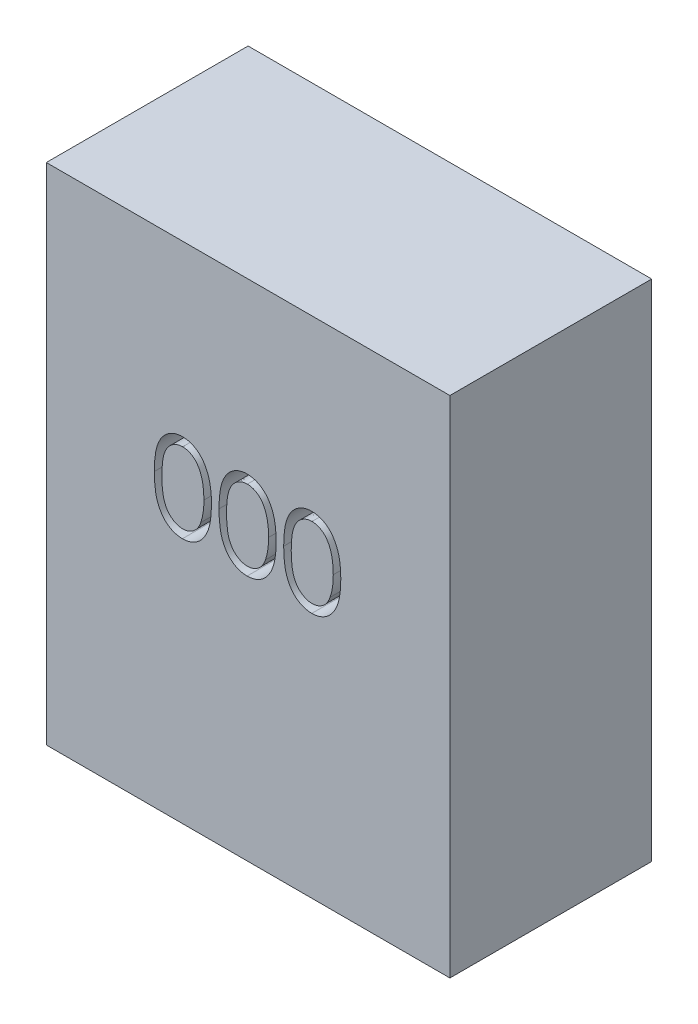
from build123d import *

# Parameters (mm, degrees)
SKETCH1_W           = 24
SKETCH1_H           = 30
BOSS_EXTRUDE1_DEPTH = 12
CUT_EXTRUDE1_DEPTH  = 2


with BuildPart() as part:
    # Sketch1 → Boss-Extrude1 (new body)
    with BuildSketch(Plane.XY):
        Rectangle(SKETCH1_W, SKETCH1_H)
    extrude(amount=BOSS_EXTRUDE1_DEPTH)

    # Sketch2 → Cut-Extrude1 (cut)
    with BuildSketch(Plane.XY.offset(12)):
        with BuildLine():
            add(Edge.make_bspline(
                [(-5.576923077, 2.298475802), (-5.57645448, 2.378614927), (-5.575544222, 2.534286333), (-5.565417907, 2.761121536), (-5.548595989, 2.973921949), (-5.525542599, 3.172697757), (-5.497488342, 3.357500278), (-5.460037647, 3.527835645), (-5.417447929, 3.684492226), (-5.368087292, 3.827980867), (-5.31239045, 3.960234728), (-5.251770078, 4.083699302), (-5.183820372, 4.198187776), (-5.112424782, 4.305527477), (-5.034693251, 4.403961327), (-4.952837836, 4.494879416), (-4.863663727, 4.576180488), (-4.770202287, 4.650246634), (-4.671607337, 4.715174451), (-4.570689243, 4.772364078), (-4.466753377, 4.821221031), (-4.359515973, 4.859635939), (-4.249940891, 4.89136572), (-4.137645081, 4.913064217), (-4.022443133, 4.926716943), (-3.94468394, 4.928022183), (-3.905248397, 4.928684135)],
                knots=[0, 0, 0, 0, 0.000240403, 0.000466987, 0.000681007, 0.000880658, 0.001067227, 0.001241486, 0.001403563, 0.001554021, 0.001696326, 0.001833841, 0.001966284, 0.002095459, 0.002220291, 0.00234224, 0.002462035, 0.002581859, 0.002699644, 0.002815804, 0.002929622, 0.00304369, 0.003157195, 0.003271518, 0.00338644, 0.003504697, 0.003504697, 0.003504697, 0.003504697], degree=3))
            add(Edge.make_bspline(
                [(-3.905248397, 4.928684135), (-3.865483428, 4.927987256), (-3.786403415, 4.926601383), (-3.669488594, 4.913281465), (-3.555274763, 4.891179861), (-3.44424885, 4.859864183), (-3.33549887, 4.821013216), (-3.22987543, 4.772317335), (-3.126722456, 4.715633239), (-3.027679188, 4.6490277), (-2.931658309, 4.574767305), (-2.841018362, 4.490820635), (-2.755751097, 4.398035322), (-2.674786375, 4.297404088), (-2.600421236, 4.186996824), (-2.529602047, 4.06873381), (-2.466213424, 3.94054686), (-2.405163888, 3.804574763), (-2.352468193, 3.657055251), (-2.304944985, 3.498819878), (-2.266546459, 3.327999612), (-2.234561784, 3.14549069), (-2.209783361, 2.950622856), (-2.19173673, 2.743813834), (-2.182203751, 2.524927562), (-2.180408464, 2.375273492), (-2.179487179, 2.298475802)],
                knots=[0, 0, 0, 0, 0.000119258, 0.000237167, 0.000352473, 0.000467905, 0.000582915, 0.000698551, 0.00081646, 0.000935634, 0.001056247, 0.001180288, 0.001305745, 0.001434012, 0.001567361, 0.001704781, 0.001847224, 0.001996109, 0.002151681, 0.002316787, 0.002491483, 0.002676571, 0.002872488, 0.003080602, 0.003299181, 0.003529585, 0.003529585, 0.003529585, 0.003529585], degree=3))
            add(Edge.make_bspline(
                [(-2.179487179, 2.298475802), (-2.180418015, 2.222013076), (-2.182231709, 2.073028573), (-2.191629861, 1.85512718), (-2.210142191, 1.649415689), (-2.233299318, 1.455400743), (-2.265372122, 1.273889859), (-2.304808074, 1.104254933), (-2.348594249, 0.945763402), (-2.402643955, 0.799713671), (-2.461802113, 0.664068352), (-2.526166679, 0.537400998), (-2.595123573, 0.418592008), (-2.670250352, 0.30859237), (-2.750326656, 0.20662286), (-2.837066354, 0.114483399), (-2.928024333, 0.029953867), (-3.024327784, -0.045262743), (-3.124915715, -0.111098179), (-3.227714396, -0.169975108), (-3.334547801, -0.217450386), (-3.442994876, -0.258214731), (-3.554606828, -0.289358233), (-3.669244529, -0.310892313), (-3.786324866, -0.325994953), (-3.865469959, -0.327147067), (-3.905248397, -0.327726122)],
                knots=[0, 0, 0, 0, 0.000229402, 0.00044698, 0.000654097, 0.000848895, 0.001032996, 0.001206716, 0.001371263, 0.001525893, 0.001673458, 0.001815007, 0.001951919, 0.002085268, 0.002214319, 0.002340458, 0.002464499, 0.002586517, 0.002706526, 0.002824923, 0.002941471, 0.003056825, 0.003172257, 0.003288547, 0.00340657, 0.003525828, 0.003525828, 0.003525828, 0.003525828], degree=3))
            add(Edge.make_bspline(
                [(-3.905248397, -0.327726122), (-3.944682846, -0.327059899), (-4.022439881, -0.32574624), (-4.137657632, -0.312155195), (-4.249489694, -0.290304476), (-4.358487914, -0.259709327), (-4.465211507, -0.222259561), (-4.568206202, -0.173468584), (-4.668617179, -0.117277057), (-4.766176545, -0.053283598), (-4.859051061, 0.020033092), (-4.947763354, 0.101124933), (-5.03008481, 0.192015521), (-5.106704946, 0.291269697), (-5.179525072, 0.397974329), (-5.246509891, 0.51358629), (-5.308468254, 0.637647162), (-5.365101812, 0.770958463), (-5.415314189, 0.915465503), (-5.459668058, 1.072821472), (-5.494688282, 1.244415238), (-5.524663933, 1.42886862), (-5.548841623, 1.626974234), (-5.565347802, 1.838839632), (-5.575549681, 2.064332787), (-5.576456924, 2.219003894), (-5.576923077, 2.298475802)],
                knots=[0, 0, 0, 0, 0.000118257, 0.00023318, 0.000347503, 0.000459772, 0.000572558, 0.000686375, 0.000801171, 0.000917569, 0.001035987, 0.001155782, 0.001277731, 0.001403351, 0.001531697, 0.001665004, 0.001803863, 0.00194748, 0.002099212, 0.002262522, 0.002437551, 0.002624279, 0.002823054, 0.003036075, 0.003261658, 0.003500058, 0.003500058, 0.003500058, 0.003500058], degree=3))
        make_face()
        with BuildLine():
            add(Edge.make_bspline(
                [(-5.128205128, 2.300479007), (-5.12803449, 2.233695151), (-5.127703313, 2.104080801), (-5.119051598, 1.915733286), (-5.107265553, 1.740061387), (-5.092063699, 1.57684205), (-5.069488059, 1.426627746), (-5.044192648, 1.288385342), (-5.013409662, 1.162846432), (-4.976988208, 1.049149559), (-4.935503784, 0.945365176), (-4.890209693, 0.848792011), (-4.841551518, 0.758289245), (-4.787095588, 0.674669804), (-4.727788355, 0.597660998), (-4.664969413, 0.525899809), (-4.596294293, 0.461904122), (-4.501288947, 0.385151472), (-4.375865412, 0.305838424), (-4.21783619, 0.236772581), (-4.055452689, 0.193369072), (-3.945236617, 0.18784942), (-3.890224359, 0.185094391)],
                knots=[0, 0, 0, 0, 0.000200331, 0.000388802, 0.000565494, 0.000728543, 0.00088039, 0.001021043, 0.001150036, 0.001267868, 0.001378906, 0.0014851, 0.001587738, 0.001686917, 0.001784078, 0.001879151, 0.001972682, 0.002065285, 0.002245351, 0.0024158, 0.002581234, 0.002746095, 0.002746095, 0.002746095, 0.002746095], degree=3))
            add(Edge.make_bspline(
                [(-3.890224359, 0.185094391), (-3.834856257, 0.187376935), (-3.724234366, 0.191937311), (-3.562614659, 0.235935507), (-3.405714273, 0.302320563), (-3.282754358, 0.380817), (-3.189207868, 0.455571756), (-3.122183596, 0.519306968), (-3.060666384, 0.590672493), (-3.002320563, 0.667671487), (-2.948807598, 0.751775036), (-2.900145972, 0.842578715), (-2.85574119, 0.940334683), (-2.830442553, 1.008577167), (-2.817508013, 1.043467789)],
                knots=[0, 0, 0, 0, 0.000165777, 0.000331211, 0.000499026, 0.000675482, 0.000766677, 0.000858065, 0.000952476, 0.001049031, 0.001147667, 0.001251187, 0.00135787, 0.001469476, 0.001469476, 0.001469476, 0.001469476], degree=3))
            add(Edge.make_bspline(
                [(-2.817508013, 1.043467789), (-2.802434059, 1.088081702), (-2.771827468, 1.17866708), (-2.732382076, 1.319186583), (-2.70131722, 1.466619103), (-2.673369554, 1.620083555), (-2.65429376, 1.780711699), (-2.638939741, 1.948006534), (-2.629895903, 2.122094194), (-2.62877483, 2.240372753), (-2.628205128, 2.300479007)],
                knots=[0, 0, 0, 0, 0.000141265, 0.000286829, 0.000437512, 0.000593125, 0.000754629, 0.00092257, 0.001097082, 0.001277395, 0.001277395, 0.001277395, 0.001277395], degree=3))
            add(Edge.make_bspline(
                [(-2.628205128, 2.300479007), (-2.628991113, 2.360575539), (-2.630528667, 2.478137203), (-2.636405792, 2.650306032), (-2.651582327, 2.813831405), (-2.668438211, 2.969417795), (-2.693291384, 3.116203941), (-2.720088251, 3.255418663), (-2.756089983, 3.38533727), (-2.794546804, 3.507993815), (-2.838561655, 3.62199475), (-2.887012704, 3.727871588), (-2.938758074, 3.82613548), (-2.994961274, 3.916516826), (-3.054955107, 3.999420458), (-3.120323035, 4.073184165), (-3.188472139, 4.140094119), (-3.283925261, 4.216469218), (-3.408888532, 4.294343069), (-3.564382314, 4.36600844), (-3.72619752, 4.407163144), (-3.835588169, 4.412965554), (-3.890224359, 4.415863622)],
                knots=[0, 0, 0, 0, 0.000180313, 0.000352732, 0.000516594, 0.000672886, 0.000822071, 0.000963108, 0.001097953, 0.001226241, 0.001348633, 0.001464269, 0.001575388, 0.001681558, 0.001783328, 0.00188198, 0.001976894, 0.002069498, 0.002248182, 0.002417204, 0.002581421, 0.002745283, 0.002745283, 0.002745283, 0.002745283], degree=3))
            add(Edge.make_bspline(
                [(-3.890224359, 4.415863622), (-3.945525205, 4.412961555), (-4.056227641, 4.407152135), (-4.21972472, 4.366161773), (-4.376445222, 4.294714679), (-4.501078043, 4.21621129), (-4.596597738, 4.141442273), (-4.663858728, 4.076604482), (-4.726924689, 4.005681261), (-4.785021403, 3.92796424), (-4.839434665, 3.844442287), (-4.88940754, 3.754458337), (-4.934432297, 3.657556388), (-4.975981634, 3.553818623), (-5.012514188, 3.44013156), (-5.042648422, 3.314747283), (-5.070487069, 3.176944581), (-5.090194596, 3.025916712), (-5.107714247, 2.862656493), (-5.118973316, 2.686546038), (-5.127732255, 2.497882638), (-5.128044347, 2.367598126), (-5.128205128, 2.300479007)],
                knots=[0, 0, 0, 0, 0.000165858, 0.000332019, 0.000501955, 0.000680639, 0.000772618, 0.000865422, 0.000960495, 0.001057049, 0.001156228, 0.00125935, 0.001365543, 0.001476581, 0.001594413, 0.001723406, 0.001863265, 0.002015963, 0.002180109, 0.002355801, 0.002545274, 0.002746606, 0.002746606, 0.002746606, 0.002746606], degree=3))
        make_face(mode=Mode.SUBTRACT)
        with BuildLine():
            add(Edge.make_bspline(
                [(-1.730769231, 2.298475802), (-1.730300633, 2.378614927), (-1.729390376, 2.534286333), (-1.719264061, 2.761121536), (-1.702442143, 2.973921949), (-1.679388753, 3.172697757), (-1.651334496, 3.357500278), (-1.613883801, 3.527835645), (-1.571294083, 3.684492226), (-1.521933446, 3.827980867), (-1.466236604, 3.960234728), (-1.405616232, 4.083699302), (-1.337666526, 4.198187776), (-1.266270936, 4.305527477), (-1.188539405, 4.403961327), (-1.10668399, 4.494879416), (-1.017509881, 4.576180488), (-0.92404844, 4.650246634), (-0.825453491, 4.715174451), (-0.724535397, 4.772364078), (-0.620599531, 4.821221031), (-0.513362127, 4.859635939), (-0.403787044, 4.89136572), (-0.291491235, 4.913064217), (-0.176289286, 4.926716943), (-0.098530094, 4.928022183), (-0.059094551, 4.928684135)],
                knots=[0, 0, 0, 0, 0.000240403, 0.000466987, 0.000681007, 0.000880658, 0.001067227, 0.001241486, 0.001403563, 0.001554021, 0.001696326, 0.001833841, 0.001966284, 0.002095459, 0.002220291, 0.00234224, 0.002462035, 0.002581859, 0.002699644, 0.002815804, 0.002929622, 0.00304369, 0.003157195, 0.003271518, 0.00338644, 0.003504697, 0.003504697, 0.003504697, 0.003504697], degree=3))
            add(Edge.make_bspline(
                [(-0.059094551, 4.928684135), (-0.019329582, 4.927987256), (0.059750431, 4.926601383), (0.176665252, 4.913281465), (0.290879083, 4.891179861), (0.401904996, 4.859864183), (0.510654977, 4.821013216), (0.616278416, 4.772317335), (0.71943139, 4.715633239), (0.818474658, 4.6490277), (0.914495537, 4.574767305), (1.005135484, 4.490820635), (1.090402749, 4.398035322), (1.171367471, 4.297404088), (1.24573261, 4.186996824), (1.316551799, 4.06873381), (1.379940422, 3.94054686), (1.440989958, 3.804574763), (1.493685653, 3.657055251), (1.541208861, 3.498819878), (1.579607387, 3.327999612), (1.611592062, 3.14549069), (1.636370485, 2.950622856), (1.654417116, 2.743813834), (1.663950095, 2.524927562), (1.665745382, 2.375273492), (1.666666667, 2.298475802)],
                knots=[0, 0, 0, 0, 0.000119258, 0.000237167, 0.000352473, 0.000467905, 0.000582915, 0.000698551, 0.00081646, 0.000935634, 0.001056247, 0.001180288, 0.001305745, 0.001434012, 0.001567361, 0.001704781, 0.001847224, 0.001996109, 0.002151681, 0.002316787, 0.002491483, 0.002676571, 0.002872488, 0.003080602, 0.003299181, 0.003529585, 0.003529585, 0.003529585, 0.003529585], degree=3))
            add(Edge.make_bspline(
                [(1.666666667, 2.298475802), (1.665735832, 2.222013076), (1.663922137, 2.073028573), (1.654523985, 1.85512718), (1.636011655, 1.649415689), (1.612854529, 1.455400743), (1.580781724, 1.273889859), (1.541345772, 1.104254933), (1.497559597, 0.945763402), (1.443509891, 0.799713671), (1.384351734, 0.664068352), (1.319987168, 0.537400998), (1.251030273, 0.418592008), (1.175903495, 0.30859237), (1.09582719, 0.20662286), (1.009087492, 0.114483399), (0.918129513, 0.029953867), (0.821826062, -0.045262743), (0.721238131, -0.111098179), (0.61843945, -0.169975108), (0.511606045, -0.217450386), (0.40315897, -0.258214731), (0.291547018, -0.289358233), (0.176909317, -0.310892313), (0.05982898, -0.325994953), (-0.019316113, -0.327147067), (-0.059094551, -0.327726122)],
                knots=[0, 0, 0, 0, 0.000229402, 0.00044698, 0.000654097, 0.000848895, 0.001032996, 0.001206716, 0.001371263, 0.001525893, 0.001673458, 0.001815007, 0.001951919, 0.002085268, 0.002214319, 0.002340458, 0.002464499, 0.002586517, 0.002706526, 0.002824923, 0.002941471, 0.003056825, 0.003172257, 0.003288547, 0.00340657, 0.003525828, 0.003525828, 0.003525828, 0.003525828], degree=3))
            add(Edge.make_bspline(
                [(-0.059094551, -0.327726122), (-0.098529, -0.327059899), (-0.176286035, -0.32574624), (-0.291503786, -0.312155195), (-0.403335848, -0.290304476), (-0.512334068, -0.259709327), (-0.619057661, -0.222259561), (-0.722052356, -0.173468584), (-0.822463333, -0.117277057), (-0.920022699, -0.053283598), (-1.012897214, 0.020033092), (-1.101609508, 0.101124933), (-1.183930964, 0.192015521), (-1.2605511, 0.291269697), (-1.333371226, 0.397974329), (-1.400356045, 0.51358629), (-1.462314408, 0.637647162), (-1.518947966, 0.770958463), (-1.569160343, 0.915465503), (-1.613514211, 1.072821472), (-1.648534436, 1.244415238), (-1.678510087, 1.42886862), (-1.702687777, 1.626974234), (-1.719193956, 1.838839632), (-1.729395835, 2.064332787), (-1.730303078, 2.219003894), (-1.730769231, 2.298475802)],
                knots=[0, 0, 0, 0, 0.000118257, 0.00023318, 0.000347503, 0.000459772, 0.000572558, 0.000686375, 0.000801171, 0.000917569, 0.001035987, 0.001155782, 0.001277731, 0.001403351, 0.001531697, 0.001665004, 0.001803863, 0.00194748, 0.002099212, 0.002262522, 0.002437551, 0.002624279, 0.002823054, 0.003036075, 0.003261658, 0.003500058, 0.003500058, 0.003500058, 0.003500058], degree=3))
        make_face()
        with BuildLine():
            add(Edge.make_bspline(
                [(-1.282051282, 2.300479007), (-1.281880643, 2.233695151), (-1.281549467, 2.104080801), (-1.272897752, 1.915733286), (-1.261111706, 1.740061387), (-1.245909853, 1.57684205), (-1.223334213, 1.426627746), (-1.198038801, 1.288385342), (-1.167255816, 1.162846432), (-1.130834362, 1.049149559), (-1.089349938, 0.945365176), (-1.044055847, 0.848792011), (-0.995397671, 0.758289245), (-0.940941742, 0.674669804), (-0.881634509, 0.597660998), (-0.818815567, 0.525899809), (-0.750140447, 0.461904122), (-0.6551351, 0.385151472), (-0.529711566, 0.305838424), (-0.371682344, 0.236772581), (-0.209298842, 0.193369072), (-0.099082771, 0.18784942), (-0.044070513, 0.185094391)],
                knots=[0, 0, 0, 0, 0.000200331, 0.000388802, 0.000565494, 0.000728543, 0.00088039, 0.001021043, 0.001150036, 0.001267868, 0.001378906, 0.0014851, 0.001587738, 0.001686917, 0.001784078, 0.001879151, 0.001972682, 0.002065285, 0.002245351, 0.0024158, 0.002581234, 0.002746095, 0.002746095, 0.002746095, 0.002746095], degree=3))
            add(Edge.make_bspline(
                [(-0.044070513, 0.185094391), (0.01129759, 0.187376935), (0.12191948, 0.191937311), (0.283539187, 0.235935507), (0.440439573, 0.302320563), (0.563399488, 0.380817), (0.656945978, 0.455571756), (0.72397025, 0.519306968), (0.785487462, 0.590672493), (0.843833283, 0.667671487), (0.897346248, 0.751775036), (0.946007874, 0.842578715), (0.990412656, 0.940334683), (1.015711293, 1.008577167), (1.028645833, 1.043467789)],
                knots=[0, 0, 0, 0, 0.000165777, 0.000331211, 0.000499026, 0.000675482, 0.000766677, 0.000858065, 0.000952476, 0.001049031, 0.001147667, 0.001251187, 0.00135787, 0.001469476, 0.001469476, 0.001469476, 0.001469476], degree=3))
            add(Edge.make_bspline(
                [(1.028645833, 1.043467789), (1.043719787, 1.088081702), (1.074326379, 1.17866708), (1.11377177, 1.319186583), (1.144836626, 1.466619103), (1.172784292, 1.620083555), (1.191860086, 1.780711699), (1.207214105, 1.948006534), (1.216257943, 2.122094194), (1.217379016, 2.240372753), (1.217948718, 2.300479007)],
                knots=[0, 0, 0, 0, 0.000141265, 0.000286829, 0.000437512, 0.000593125, 0.000754629, 0.00092257, 0.001097082, 0.001277395, 0.001277395, 0.001277395, 0.001277395], degree=3))
            add(Edge.make_bspline(
                [(1.217948718, 2.300479007), (1.217162733, 2.360575539), (1.215625179, 2.478137203), (1.209748054, 2.650306032), (1.194571519, 2.813831405), (1.177715635, 2.969417795), (1.152862462, 3.116203941), (1.126065595, 3.255418663), (1.090063863, 3.38533727), (1.051607042, 3.507993815), (1.007592191, 3.62199475), (0.959141142, 3.727871588), (0.907395772, 3.82613548), (0.851192572, 3.916516826), (0.791198739, 3.999420458), (0.725830811, 4.073184165), (0.657681707, 4.140094119), (0.562228585, 4.216469218), (0.437265314, 4.294343069), (0.281771532, 4.36600844), (0.119956326, 4.407163144), (0.010565677, 4.412965554), (-0.044070513, 4.415863622)],
                knots=[0, 0, 0, 0, 0.000180313, 0.000352732, 0.000516594, 0.000672886, 0.000822071, 0.000963108, 0.001097953, 0.001226241, 0.001348633, 0.001464269, 0.001575388, 0.001681558, 0.001783328, 0.00188198, 0.001976894, 0.002069498, 0.002248182, 0.002417204, 0.002581421, 0.002745283, 0.002745283, 0.002745283, 0.002745283], degree=3))
            add(Edge.make_bspline(
                [(-0.044070513, 4.415863622), (-0.099371359, 4.412961555), (-0.210073795, 4.407152135), (-0.373570873, 4.366161773), (-0.530291376, 4.294714679), (-0.654924197, 4.21621129), (-0.750443892, 4.141442273), (-0.817704882, 4.076604482), (-0.880770843, 4.005681261), (-0.938867557, 3.92796424), (-0.993280819, 3.844442287), (-1.043253694, 3.754458337), (-1.088278451, 3.657556388), (-1.129827788, 3.553818623), (-1.166360342, 3.44013156), (-1.196494575, 3.314747283), (-1.224333223, 3.176944581), (-1.24404075, 3.025916712), (-1.261560401, 2.862656493), (-1.272819469, 2.686546038), (-1.281578409, 2.497882638), (-1.281890501, 2.367598126), (-1.282051282, 2.300479007)],
                knots=[0, 0, 0, 0, 0.000165858, 0.000332019, 0.000501955, 0.000680639, 0.000772618, 0.000865422, 0.000960495, 0.001057049, 0.001156228, 0.00125935, 0.001365543, 0.001476581, 0.001594413, 0.001723406, 0.001863265, 0.002015963, 0.002180109, 0.002355801, 0.002545274, 0.002746606, 0.002746606, 0.002746606, 0.002746606], degree=3))
        make_face(mode=Mode.SUBTRACT)
        with BuildLine():
            add(Edge.make_bspline(
                [(2.115384615, 2.298475802), (2.115853213, 2.378614927), (2.11676347, 2.534286333), (2.126889786, 2.761121536), (2.143711703, 2.973921949), (2.166765093, 3.172697757), (2.19481935, 3.357500278), (2.232270046, 3.527835645), (2.274859764, 3.684492226), (2.3242204, 3.827980867), (2.379917242, 3.960234728), (2.440537614, 4.083699302), (2.508487321, 4.198187776), (2.579882911, 4.305527477), (2.657614441, 4.403961327), (2.739469856, 4.494879416), (2.828643965, 4.576180488), (2.922105406, 4.650246634), (3.020700355, 4.715174451), (3.121618449, 4.772364078), (3.225554315, 4.821221031), (3.332791719, 4.859635939), (3.442366802, 4.89136572), (3.554662611, 4.913064217), (3.66986456, 4.926716943), (3.747623752, 4.928022183), (3.787059295, 4.928684135)],
                knots=[0, 0, 0, 0, 0.000240403, 0.000466987, 0.000681007, 0.000880658, 0.001067227, 0.001241486, 0.001403563, 0.001554021, 0.001696326, 0.001833841, 0.001966284, 0.002095459, 0.002220291, 0.00234224, 0.002462035, 0.002581859, 0.002699644, 0.002815804, 0.002929622, 0.00304369, 0.003157195, 0.003271518, 0.00338644, 0.003504697, 0.003504697, 0.003504697, 0.003504697], degree=3))
            add(Edge.make_bspline(
                [(3.787059295, 4.928684135), (3.826824264, 4.927987256), (3.905904277, 4.926601383), (4.022819099, 4.913281465), (4.13703293, 4.891179861), (4.248058842, 4.859864183), (4.356808823, 4.821013216), (4.462432262, 4.772317335), (4.565585236, 4.715633239), (4.664628504, 4.6490277), (4.760649383, 4.574767305), (4.85128933, 4.490820635), (4.936556596, 4.398035322), (5.017521318, 4.297404088), (5.091886456, 4.186996824), (5.162705645, 4.06873381), (5.226094268, 3.94054686), (5.287143804, 3.804574763), (5.339839499, 3.657055251), (5.387362707, 3.498819878), (5.425761233, 3.327999612), (5.457745908, 3.14549069), (5.482524331, 2.950622856), (5.500570963, 2.743813834), (5.510103941, 2.524927562), (5.511899229, 2.375273492), (5.512820513, 2.298475802)],
                knots=[0, 0, 0, 0, 0.000119258, 0.000237167, 0.000352473, 0.000467905, 0.000582915, 0.000698551, 0.00081646, 0.000935634, 0.001056247, 0.001180288, 0.001305745, 0.001434012, 0.001567361, 0.001704781, 0.001847224, 0.001996109, 0.002151681, 0.002316787, 0.002491483, 0.002676571, 0.002872488, 0.003080602, 0.003299181, 0.003529585, 0.003529585, 0.003529585, 0.003529585], degree=3))
            add(Edge.make_bspline(
                [(5.512820513, 2.298475802), (5.511889678, 2.222013076), (5.510075984, 2.073028573), (5.500677831, 1.85512718), (5.482165501, 1.649415689), (5.459008375, 1.455400743), (5.42693557, 1.273889859), (5.387499619, 1.104254933), (5.343713443, 0.945763402), (5.289663737, 0.799713671), (5.23050558, 0.664068352), (5.166141014, 0.537400998), (5.097184119, 0.418592008), (5.022057341, 0.30859237), (4.941981036, 0.20662286), (4.855241338, 0.114483399), (4.764283359, 0.029953867), (4.667979908, -0.045262743), (4.567391978, -0.111098179), (4.464593296, -0.169975108), (4.357759892, -0.217450386), (4.249312816, -0.258214731), (4.137700865, -0.289358233), (4.023063164, -0.310892313), (3.905982827, -0.325994953), (3.826837734, -0.327147067), (3.787059295, -0.327726122)],
                knots=[0, 0, 0, 0, 0.000229402, 0.00044698, 0.000654097, 0.000848895, 0.001032996, 0.001206716, 0.001371263, 0.001525893, 0.001673458, 0.001815007, 0.001951919, 0.002085268, 0.002214319, 0.002340458, 0.002464499, 0.002586517, 0.002706526, 0.002824923, 0.002941471, 0.003056825, 0.003172257, 0.003288547, 0.00340657, 0.003525828, 0.003525828, 0.003525828, 0.003525828], degree=3))
            add(Edge.make_bspline(
                [(3.787059295, -0.327726122), (3.747624846, -0.327059899), (3.669867811, -0.32574624), (3.55465006, -0.312155195), (3.442817998, -0.290304476), (3.333819778, -0.259709327), (3.227096185, -0.222259561), (3.12410149, -0.173468584), (3.023690513, -0.117277057), (2.926131148, -0.053283598), (2.833256632, 0.020033092), (2.744544338, 0.101124933), (2.662222883, 0.192015521), (2.585602746, 0.291269697), (2.51278262, 0.397974329), (2.445797801, 0.51358629), (2.383839438, 0.637647162), (2.32720588, 0.770958463), (2.276993504, 0.915465503), (2.232639635, 1.072821472), (2.19761941, 1.244415238), (2.167643759, 1.42886862), (2.143466069, 1.626974234), (2.12695989, 1.838839632), (2.116758012, 2.064332787), (2.115850768, 2.219003894), (2.115384615, 2.298475802)],
                knots=[0, 0, 0, 0, 0.000118257, 0.00023318, 0.000347503, 0.000459772, 0.000572558, 0.000686375, 0.000801171, 0.000917569, 0.001035987, 0.001155782, 0.001277731, 0.001403351, 0.001531697, 0.001665004, 0.001803863, 0.00194748, 0.002099212, 0.002262522, 0.002437551, 0.002624279, 0.002823054, 0.003036075, 0.003261658, 0.003500058, 0.003500058, 0.003500058, 0.003500058], degree=3))
        make_face()
        with BuildLine():
            add(Edge.make_bspline(
                [(2.564102564, 2.300479007), (2.564273203, 2.233695151), (2.564604379, 2.104080801), (2.573256094, 1.915733286), (2.58504214, 1.740061387), (2.600243993, 1.57684205), (2.622819634, 1.426627746), (2.648115045, 1.288385342), (2.67889803, 1.162846432), (2.715319484, 1.049149559), (2.756803908, 0.945365176), (2.802097999, 0.848792011), (2.850756175, 0.758289245), (2.905212104, 0.674669804), (2.964519337, 0.597660998), (3.027338279, 0.525899809), (3.096013399, 0.461904122), (3.191018746, 0.385151472), (3.316442281, 0.305838424), (3.474471502, 0.236772581), (3.636855004, 0.193369072), (3.747071075, 0.18784942), (3.802083333, 0.185094391)],
                knots=[0, 0, 0, 0, 0.000200331, 0.000388802, 0.000565494, 0.000728543, 0.00088039, 0.001021043, 0.001150036, 0.001267868, 0.001378906, 0.0014851, 0.001587738, 0.001686917, 0.001784078, 0.001879151, 0.001972682, 0.002065285, 0.002245351, 0.0024158, 0.002581234, 0.002746095, 0.002746095, 0.002746095, 0.002746095], degree=3))
            add(Edge.make_bspline(
                [(3.802083333, 0.185094391), (3.857451436, 0.187376935), (3.968073326, 0.191937311), (4.129693033, 0.235935507), (4.286593419, 0.302320563), (4.409553334, 0.380817), (4.503099825, 0.455571756), (4.570124096, 0.519306968), (4.631641308, 0.590672493), (4.689987129, 0.667671487), (4.743500095, 0.751775036), (4.79216172, 0.842578715), (4.836566502, 0.940334683), (4.861865139, 1.008577167), (4.874799679, 1.043467789)],
                knots=[0, 0, 0, 0, 0.000165777, 0.000331211, 0.000499026, 0.000675482, 0.000766677, 0.000858065, 0.000952476, 0.001049031, 0.001147667, 0.001251187, 0.00135787, 0.001469476, 0.001469476, 0.001469476, 0.001469476], degree=3))
            add(Edge.make_bspline(
                [(4.874799679, 1.043467789), (4.889873633, 1.088081702), (4.920480225, 1.17866708), (4.959925616, 1.319186583), (4.990990472, 1.466619103), (5.018938138, 1.620083555), (5.038013932, 1.780711699), (5.053367951, 1.948006534), (5.062411789, 2.122094194), (5.063532862, 2.240372753), (5.064102564, 2.300479007)],
                knots=[0, 0, 0, 0, 0.000141265, 0.000286829, 0.000437512, 0.000593125, 0.000754629, 0.00092257, 0.001097082, 0.001277395, 0.001277395, 0.001277395, 0.001277395], degree=3))
            add(Edge.make_bspline(
                [(5.064102564, 2.300479007), (5.063316579, 2.360575539), (5.061779026, 2.478137203), (5.0559019, 2.650306032), (5.040725365, 2.813831405), (5.023869481, 2.969417795), (4.999016308, 3.116203941), (4.972219441, 3.255418663), (4.936217709, 3.38533727), (4.897760888, 3.507993815), (4.853746037, 3.62199475), (4.805294988, 3.727871588), (4.753549619, 3.82613548), (4.697346418, 3.916516826), (4.637352585, 3.999420458), (4.571984658, 4.073184165), (4.503835554, 4.140094119), (4.408382431, 4.216469218), (4.28341916, 4.294343069), (4.127925378, 4.36600844), (3.966110172, 4.407163144), (3.856719523, 4.412965554), (3.802083333, 4.415863622)],
                knots=[0, 0, 0, 0, 0.000180313, 0.000352732, 0.000516594, 0.000672886, 0.000822071, 0.000963108, 0.001097953, 0.001226241, 0.001348633, 0.001464269, 0.001575388, 0.001681558, 0.001783328, 0.00188198, 0.001976894, 0.002069498, 0.002248182, 0.002417204, 0.002581421, 0.002745283, 0.002745283, 0.002745283, 0.002745283], degree=3))
            add(Edge.make_bspline(
                [(3.802083333, 4.415863622), (3.746782487, 4.412961555), (3.636080051, 4.407152135), (3.472582973, 4.366161773), (3.31586247, 4.294714679), (3.191229649, 4.21621129), (3.095709954, 4.141442273), (3.028448964, 4.076604482), (2.965383004, 4.005681261), (2.907286289, 3.92796424), (2.852873027, 3.844442287), (2.802900152, 3.754458337), (2.757875396, 3.657556388), (2.716326058, 3.553818623), (2.679793504, 3.44013156), (2.649659271, 3.314747283), (2.621820623, 3.176944581), (2.602113096, 3.025916712), (2.584593445, 2.862656493), (2.573334377, 2.686546038), (2.564575438, 2.497882638), (2.564263346, 2.367598126), (2.564102564, 2.300479007)],
                knots=[0, 0, 0, 0, 0.000165858, 0.000332019, 0.000501955, 0.000680639, 0.000772618, 0.000865422, 0.000960495, 0.001057049, 0.001156228, 0.00125935, 0.001365543, 0.001476581, 0.001594413, 0.001723406, 0.001863265, 0.002015963, 0.002180109, 0.002355801, 0.002545274, 0.002746606, 0.002746606, 0.002746606, 0.002746606], degree=3))
        make_face(mode=Mode.SUBTRACT)
    extrude(amount=-CUT_EXTRUDE1_DEPTH, mode=Mode.SUBTRACT)


solid = part.part
